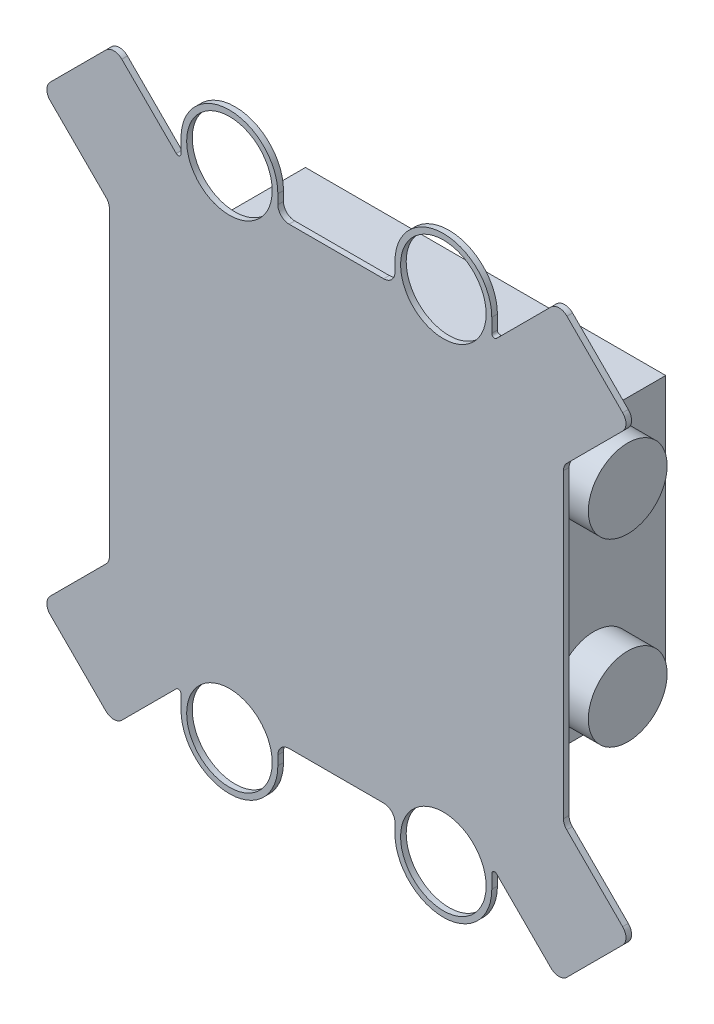
from build123d import *

# Parameters (mm, degrees)
BOSS_EXTRUDE1_DEPTH = 6.35
SKETCH2_W           = 406.4
SKETCH2_H           = 304.8
BOSS_EXTRUDE2_DEPTH = 161.925
SKETCH3_R           = 48.26
CUT_EXTRUDE1_DEPTH  = 161.925
SKETCH4_R           = 44.45
BOSS_EXTRUDE3_DEPTH = 38.1


with BuildPart() as part:
    # Sketch1 → Boss-Extrude1 (new body)
    with BuildSketch(Plane.XY):
        with BuildLine():
            Line((256.082305134, -169.999487802), (256.082305134, 169.999487802))
            ThreePointArc((256.082305134, 169.999487802), (257.049035071, 174.859567393), (259.802049013, 178.979743923))
            Line((259.802049013, 178.979743923), (322.888153673, 242.065848583))
            ThreePointArc((322.888153673, 242.065848583), (326.607897552, 251.046104704), (322.888153673, 260.026360825))
            Line((322.888153673, 260.026360825), (260.026360825, 322.888153673))
            ThreePointArc((260.026360825, 322.888153673), (251.046104704, 326.607897552), (242.065848583, 322.888153673))
            Line((242.065848583, 322.888153673), (180.680064074, 261.502369164))
            ThreePointArc((180.680064074, 261.502369164), (177.219980146, 260.814115678), (175.260000044, 263.747433194))
            Line((175.260000044, 263.747433194), (175.260000044, 279.4))
            ThreePointArc((175.260000044, 279.4), (120.65, 334.010000044), (66.039999956, 279.4))
            Line((66.039999956, 279.4), (66.039999956, 268.782305134))
            ThreePointArc((66.039999956, 268.782305134), (62.320256077, 259.802049013), (53.339999956, 256.082305134))
            Line((53.339999956, 256.082305134), (-53.339999956, 256.082305134))
            ThreePointArc((-53.339999956, 256.082305134), (-62.320256077, 259.802049013), (-66.039999956, 268.782305134))
            Line((-66.039999956, 268.782305134), (-66.039999956, 279.4))
            ThreePointArc((-66.039999956, 279.4), (-120.65, 334.010000044), (-175.260000044, 279.4))
            Line((-175.260000044, 279.4), (-175.260000044, 263.747433194))
            ThreePointArc((-175.260000044, 263.747433194), (-177.219980146, 260.814115678), (-180.680064074, 261.502369164))
            Line((-180.680064074, 261.502369164), (-242.065848583, 322.888153673))
            ThreePointArc((-242.065848583, 322.888153673), (-251.046104704, 326.607897552), (-260.026360825, 322.888153673))
            Line((-260.026360825, 322.888153673), (-322.888153673, 260.026360825))
            ThreePointArc((-322.888153673, 260.026360825), (-326.607897552, 251.046104704), (-322.888153673, 242.065848583))
            Line((-322.888153673, 242.065848583), (-259.802049013, 178.979743923))
            ThreePointArc((-259.802049013, 178.979743923), (-257.049035071, 174.859567393), (-256.082305134, 169.999487802))
            Line((-256.082305134, 169.999487802), (-256.082305134, -169.999487802))
            ThreePointArc((-256.082305134, -169.999487802), (-257.049035071, -174.859567393), (-259.802049013, -178.979743923))
            Line((-259.802049013, -178.979743923), (-322.888153673, -242.065848583))
            ThreePointArc((-322.888153673, -242.065848583), (-326.607897552, -251.046104704), (-322.888153673, -260.026360825))
            Line((-322.888153673, -260.026360825), (-260.026360825, -322.888153673))
            ThreePointArc((-260.026360825, -322.888153673), (-251.046104704, -326.607897552), (-242.065848583, -322.888153673))
            Line((-242.065848583, -322.888153673), (-180.680064074, -261.502369164))
            ThreePointArc((-180.680064074, -261.502369164), (-177.219980146, -260.814115678), (-175.260000044, -263.747433194))
            Line((-175.260000044, -263.747433194), (-175.260000044, -279.4))
            ThreePointArc((-175.260000044, -279.4), (-120.65, -334.010000044), (-66.039999956, -279.4))
            Line((-66.039999956, -279.4), (-66.039999956, -268.782305134))
            ThreePointArc((-66.039999956, -268.782305134), (-62.320256077, -259.802049013), (-53.339999956, -256.082305134))
            Line((-53.339999956, -256.082305134), (53.339999956, -256.082305134))
            ThreePointArc((53.339999956, -256.082305134), (62.320256077, -259.802049013), (66.039999956, -268.782305134))
            Line((66.039999956, -268.782305134), (66.039999956, -279.4))
            ThreePointArc((66.039999956, -279.4), (120.65, -334.010000044), (175.260000044, -279.4))
            Line((175.260000044, -279.4), (175.260000044, -263.747433194))
            ThreePointArc((175.260000044, -263.747433194), (177.219980146, -260.814115678), (180.680064074, -261.502369164))
            Line((180.680064074, -261.502369164), (242.065848583, -322.888153673))
            ThreePointArc((242.065848583, -322.888153673), (251.046104704, -326.607897552), (260.026360825, -322.888153673))
            Line((260.026360825, -322.888153673), (322.888153673, -260.026360825))
            ThreePointArc((322.888153673, -260.026360825), (326.607897552, -251.046104704), (322.888153673, -242.065848583))
            Line((322.888153673, -242.065848583), (259.802049013, -178.979743923))
            ThreePointArc((259.802049013, -178.979743923), (257.049035071, -174.859567393), (256.082305134, -169.999487802))
        make_face()
    extrude(amount=BOSS_EXTRUDE1_DEPTH)

    # Sketch2 → Boss-Extrude2 (add)
    with BuildSketch(Plane(origin=(0, 0, 0), x_dir=(-1, 0, 0), z_dir=(0, 0, -1))):
        Rectangle(SKETCH2_W, SKETCH2_H)
    extrude(amount=BOSS_EXTRUDE2_DEPTH)

    # Sketch3 → Cut-Extrude1 (cut)
    with BuildSketch(Plane(origin=(0, 0, 0), x_dir=(-1, 0, 0), z_dir=(0, 0, -1))):
        with Locations((120.65, 279.4)):
            Circle(SKETCH3_R)
        with Locations((-120.65, 279.4)):
            Circle(SKETCH3_R)
        with Locations((-120.65, -279.4)):
            Circle(SKETCH3_R)
        with Locations((120.65, -279.4)):
            Circle(SKETCH3_R)
    extrude(amount=-CUT_EXTRUDE1_DEPTH, mode=Mode.SUBTRACT)

    # Sketch4 → Boss-Extrude3 (add)
    with BuildSketch(Plane(origin=(203.2, 0, 0), x_dir=(0, 0, -1), z_dir=(1, 0, 0))):
        with Locations((80.9625, 101.6)):
            Circle(SKETCH4_R)
        with Locations((80.9625, -101.6)):
            Circle(SKETCH4_R)
    extrude(amount=BOSS_EXTRUDE3_DEPTH)


solid = part.part
